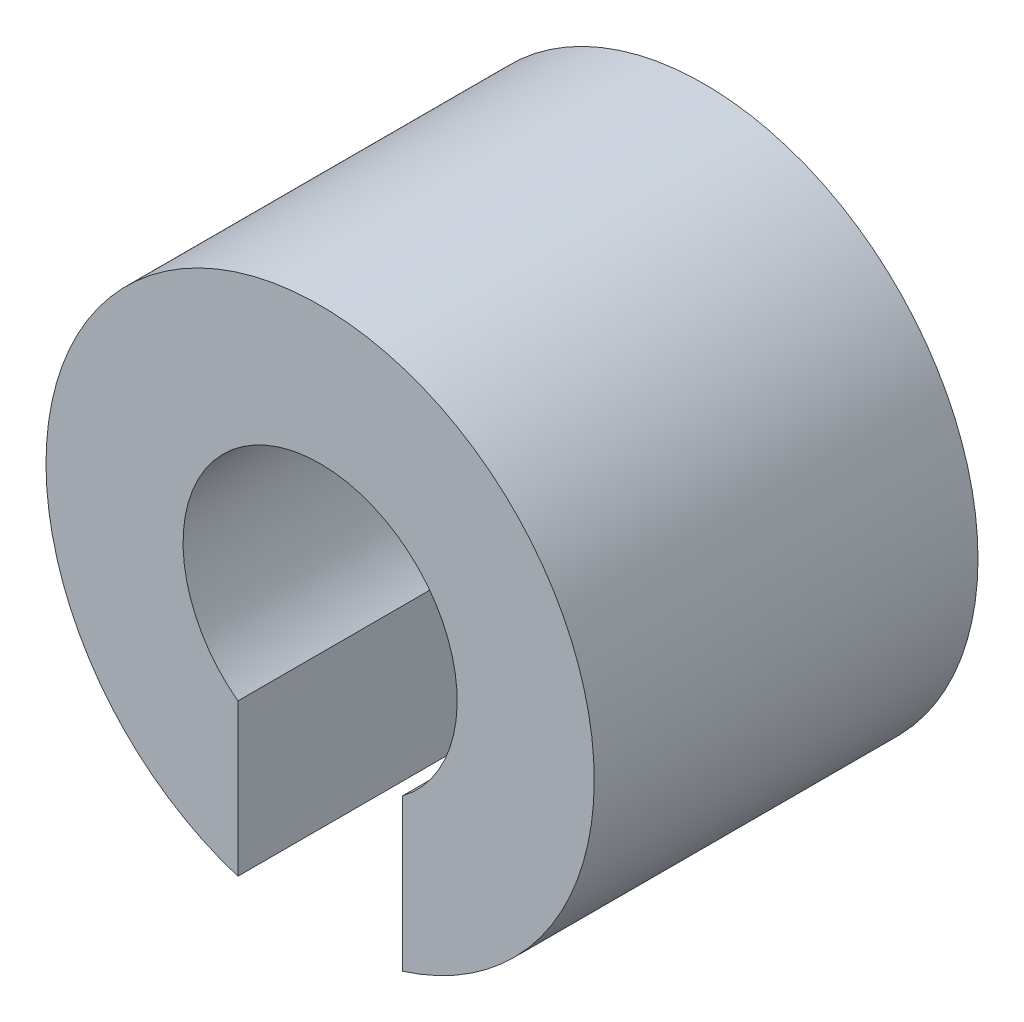
from build123d import *

# Parameters (mm, degrees)
EXTRUDE_1_DEPTH = 7


with BuildPart() as part:
    # ｽｹｯﾁ1 → ﾎﾞｽ - 押し出し1 (new body)
    with BuildSketch(Plane.XY):
        with BuildLine():
            Line((-1.5, -4.769696007), (-1.5, -2))
            ThreePointArc((-1.5, -2), (0, 2.5), (1.5, -2))
            Line((1.5, -2), (1.5, -4.769696007))
            ThreePointArc((1.5, -4.769696007), (0, 5), (-1.5, -4.769696007))
        make_face()
    extrude(amount=EXTRUDE_1_DEPTH)


solid = part.part
